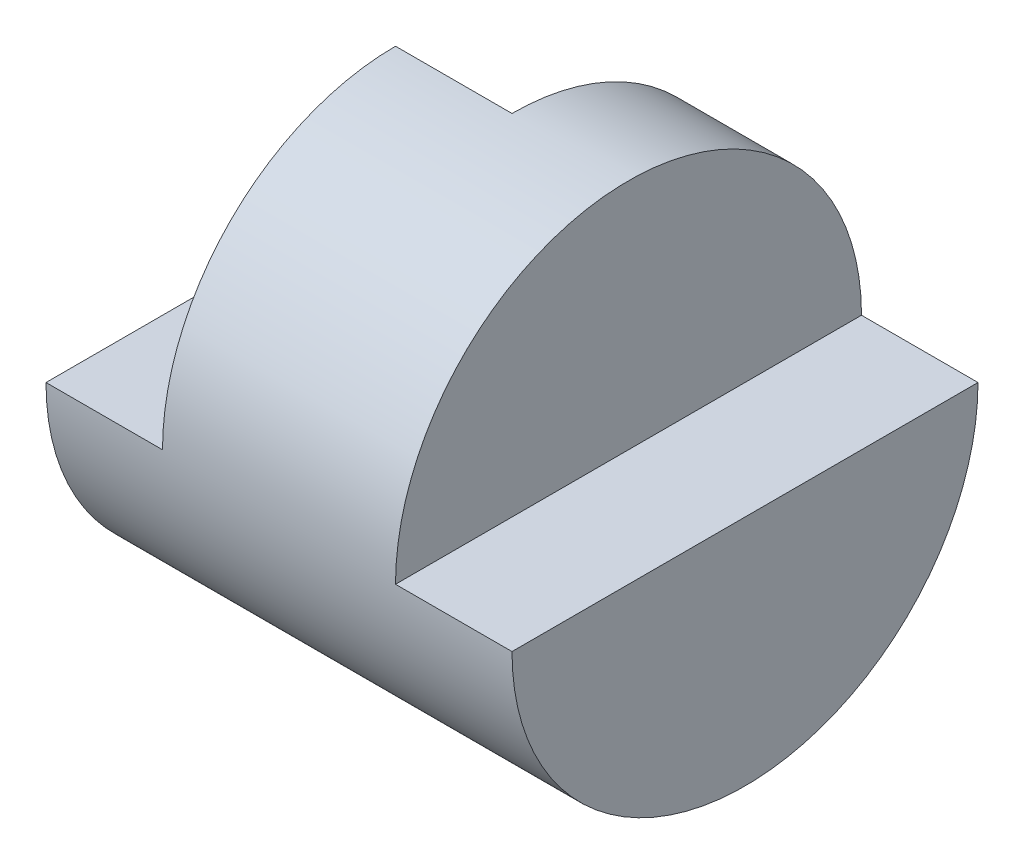
from build123d import *

# Parameters (mm, degrees)
SKETCH5_W          = 4
SKETCH5_H          = 2
SKETCH6_W          = 1
SKETCH6_H          = 2
CUT_EXTRUDE5_DEPTH = 5.5
SKETCH7_W          = 1
SKETCH7_H          = 2
CUT_EXTRUDE6_DEPTH = 3


with BuildPart() as part:
    # Sketch5 → Revolve-Thin2 (revolve)
    with BuildSketch(Plane.XY):
        with Locations((2, 1)):
            Rectangle(SKETCH5_W, SKETCH5_H)
    revolve(axis=Axis((0, 0, 0), (1, 0, 0)))

    # Sketch6 → Cut-Extrude5 (cut, symmetric)
    with BuildSketch(Plane.XY):
        with Locations((3.5, 1)):
            Rectangle(SKETCH6_W, SKETCH6_H)
        with Locations((0.5, 1)):
            Rectangle(SKETCH6_W, SKETCH6_H)
    extrude(amount=CUT_EXTRUDE5_DEPTH, both=True, mode=Mode.SUBTRACT)

    # Sketch7 → Cut-Extrude6 (cut)
    with BuildSketch(Plane(origin=(0, 0, 0), x_dir=(1, 0, 0), z_dir=(0, 1, 0))):
        with Locations((1.5, 1)):
            Rectangle(SKETCH7_W, SKETCH7_H)
    extrude(amount=CUT_EXTRUDE6_DEPTH, mode=Mode.SUBTRACT)


solid = part.part
